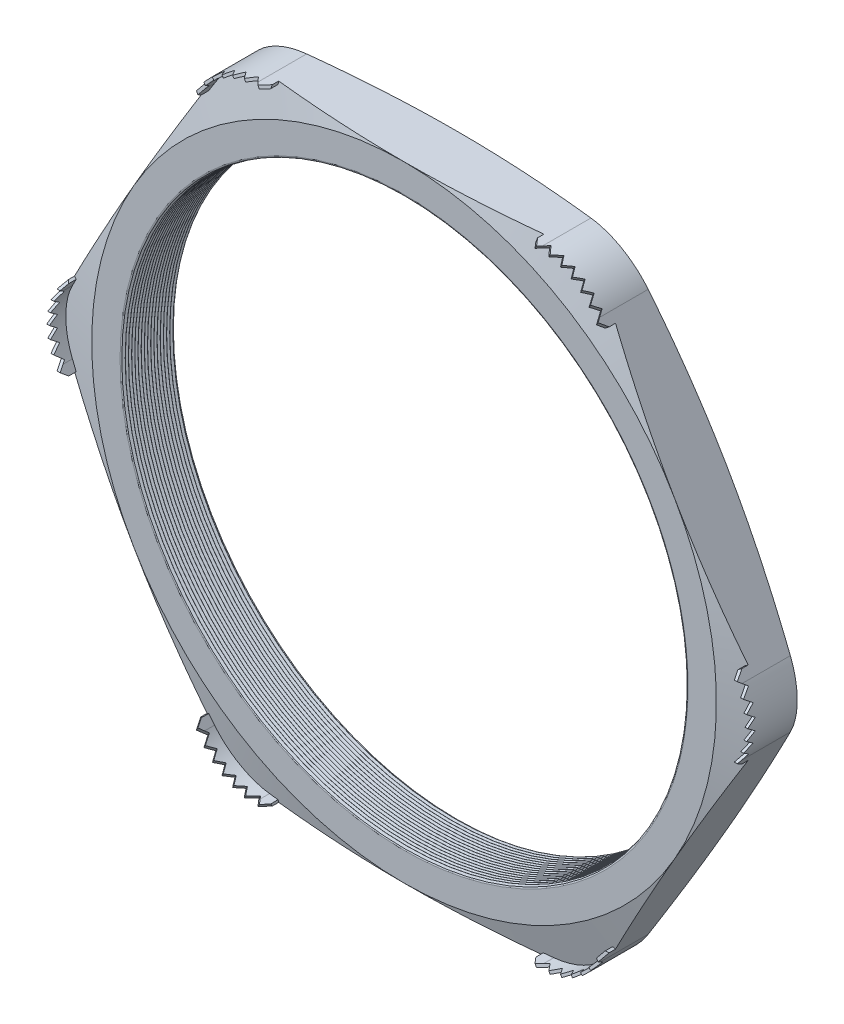
from build123d import *

# Parameters (mm, degrees)
SKETCH1_R          = 27.051
EXTRUDE1_DEPTH     = 5.08
FILLET1_R          = 6.35
FILLET3_R          = 0.2032
LPATTERN1_COUNT    = 17
LPATTERN1_PITCH    = 0.3048
SKETCH4_OUTSIDE_W  = 132.68
SKETCH4_OUTSIDE_H  = 125.372
SKETCH4_OUTSIDE_R  = 29.972
CUT_EXTRUDE1_DEPTH = 6.08
CUT_EXTRUDE1_DRAFT = -75
SKETCH5_OUTSIDE_W  = 132.68
SKETCH5_OUTSIDE_H  = 125.372
SKETCH5_OUTSIDE_R  = 29.972
CUT_EXTRUDE2_DEPTH = 6.0800001
CUT_EXTRUDE2_DRAFT = -75
EXTRUDE2_START     = -0.979177
EXTRUDE2_DEPTH     = 2.757177
CUT_EXTRUDE4_DEPTH = 11.671254619
CIRPATTERN1_COUNT  = 6
CIRPATTERN2_COUNT  = 6


with BuildPart() as part:
    # Sketch1 → Extrude1 (new body)
    with BuildSketch(Plane.XY):
        Polygon((-34.608684536, 0), (-17.304342268, -29.972), (17.304342268, -29.972), (34.608684536, 0), (17.304342268, 29.972), (-17.304342268, 29.972), align=None)
        Circle(SKETCH1_R, mode=Mode.SUBTRACT)
    extrude(amount=EXTRUDE1_DEPTH)

    # Fillet1
    fillet1_edges = [part.edges().sort_by_distance(p)[0] for p in [
        (34.608684536, 0, 2.54),
        (17.304342268, -29.972, 2.54),
        (-17.304342268, -29.972, 2.54),
        (-34.608684536, 0, 2.54),
        (-17.304342268, 29.972, 2.54),
        (17.304342268, 29.972, 2.54),
    ]]
    fillet(fillet1_edges, radius=FILLET1_R)

    # Fillet3
    fillet3_edges = [part.edges().sort_by_distance(p)[0] for p in [
        (-27.051, 0, 0),
        (-27.051, 0, 5.08),
    ]]
    fillet(fillet3_edges, radius=FILLET3_R)

    # Sketch3 → Cut-Revolve1 (revolve, cut)
    with BuildSketch(Plane(origin=(0, 0, 0), x_dir=(1, 0, 0), z_dir=(0, 1, 0))):
        Polygon((-27.051, -5.08), (-27.051, -4.786706063), (-27.305, -4.933353032), align=None)
    cut_revolve1 = revolve(axis=Axis((0, 0, 5.08), (0, 0, -1)), mode=Mode.SUBTRACT)

    # LPattern1: Cut-Revolve1 ×17
    with Locations(*[(0, 0, -i * LPATTERN1_PITCH) for i in range(1, LPATTERN1_COUNT)]):
        add(cut_revolve1, mode=Mode.SUBTRACT)


with BuildPart() as cut_extrude1_tool:
    # Sketch4 outside → Cut-Extrude1 (with draft: the straight prism first)
    with BuildSketch(Plane(origin=(0, 0, 0), x_dir=(-1, 0, 0), z_dir=(0, 0, -1))):
        Rectangle(SKETCH4_OUTSIDE_W, SKETCH4_OUTSIDE_H)
        Circle(SKETCH4_OUTSIDE_R, mode=Mode.SUBTRACT)
    extrude(amount=-CUT_EXTRUDE1_DEPTH)
    # Cut-Extrude1: the draft: its side faces are tilted about the plane it starts from
    cut_extrude1_sides = [cut_extrude1_tool.faces().sort_by_distance(p)[0] for p in [
        (0, -62.686, 3.04),
        (-66.34, 0, 3.04),
        (0, 62.686, 3.04),
        (66.34, 0, 3.04),
        (29.972, 0, 3.04),
    ]]
    draft(cut_extrude1_sides, Plane(origin=(0, 0, 0), x_dir=(-1, 0, 0), z_dir=(0, 0, -1)), CUT_EXTRUDE1_DRAFT)


with BuildPart() as part_1:
    add(part.part)

    # Cut-Extrude1: cut by cut_extrude1_tool
    add(cut_extrude1_tool.part, mode=Mode.SUBTRACT)


with BuildPart() as cut_extrude2_tool:
    # Sketch5 outside → Cut-Extrude2 (with draft: the straight prism first)
    with BuildSketch(Plane.XY.offset(5.08)):
        Rectangle(SKETCH5_OUTSIDE_W, SKETCH5_OUTSIDE_H)
        Circle(SKETCH5_OUTSIDE_R, mode=Mode.SUBTRACT)
    extrude(amount=-CUT_EXTRUDE2_DEPTH)
    # Cut-Extrude2: the draft: its side faces are tilted about the plane it starts from
    cut_extrude2_sides = [cut_extrude2_tool.faces().sort_by_distance(p)[0] for p in [
        (0, -62.686, 2.03999995),
        (66.34, 0, 2.03999995),
        (0, 62.686, 2.03999995),
        (-66.34, 0, 2.03999995),
        (-29.972, 0, 2.03999995),
    ]]
    draft(cut_extrude2_sides, Plane.XY.offset(5.08), CUT_EXTRUDE2_DRAFT)


with BuildPart() as part_2:
    add(part_1.part)

    # Cut-Extrude2: cut by cut_extrude2_tool
    add(cut_extrude2_tool.part, mode=Mode.SUBTRACT)

    # Sketch2 → Extrude2 (add)
    with BuildSketch(Plane.XY.offset(5.08).offset(EXTRUDE2_START)):
        with BuildLine():
            Line((-13.638168059, 29.972), (-12.723768059, 29.972))
            Line((-12.723768059, 29.972), (-12.723768059, 29.718))
            Line((-12.723768059, 29.718), (-13.638168059, 29.718))
            ThreePointArc((-13.638168059, 29.718), (-16.686168059, 28.901290861), (-18.91745892, 26.67))
            Line((-18.91745892, 26.67), (-19.37465892, 25.878106371))
            Line((-19.37465892, 25.878106371), (-19.594629373, 26.005106371))
            Line((-19.594629373, 26.005106371), (-19.137429373, 26.797))
            ThreePointArc((-19.137429373, 26.797), (-16.813168059, 29.121261314), (-13.638168059, 29.972))
        make_face()
    extrude2 = extrude(amount=EXTRUDE2_DEPTH)

    # Sketch7 → Cut-Extrude4 (cut, through all)
    with BuildSketch(Plane(origin=(-16.04921349, 27.798053185, 0), x_dir=(0.866025404, 0.5, 0), z_dir=(0.5, -0.866025404, 0))):
        Polygon((-3.966893629, 4.9911), (-3.408093629, 5.73786), (-2.849293629, 4.9911), (-2.2352, 5.73786), (-1.6764, 4.9911), (-1.1176, 5.73786), (-0.5588, 4.9911), (0, 5.73786), (0.5588, 4.9911), (1.1176, 5.73786), (1.6764, 4.9911), (2.2352, 5.73786), (2.794, 4.9911), (3.408093629, 5.73786), (3.966893629, 4.9911), (3.966893629, 6.858), (-3.966893629, 6.858), align=None)
    cut_extrude4 = extrude(amount=-CUT_EXTRUDE4_DEPTH, mode=Mode.SUBTRACT)

    # CirPattern1: Extrude2 ×6 about axis
    cirpattern1_axis = Axis((0, 0, 0), (0, 0, 1))
    for i in range(1, CIRPATTERN1_COUNT):
        add(extrude2.rotate(cirpattern1_axis, i * 360 / CIRPATTERN1_COUNT))

    # CirPattern2: Cut-Extrude4 ×6 about axis
    cirpattern2_axis = Axis((0, 0, 0), (0, 0, 1))
    for i in range(1, CIRPATTERN2_COUNT):
        add(cut_extrude4.rotate(cirpattern2_axis, i * 360 / CIRPATTERN2_COUNT), mode=Mode.SUBTRACT)


solid = part_2.part
